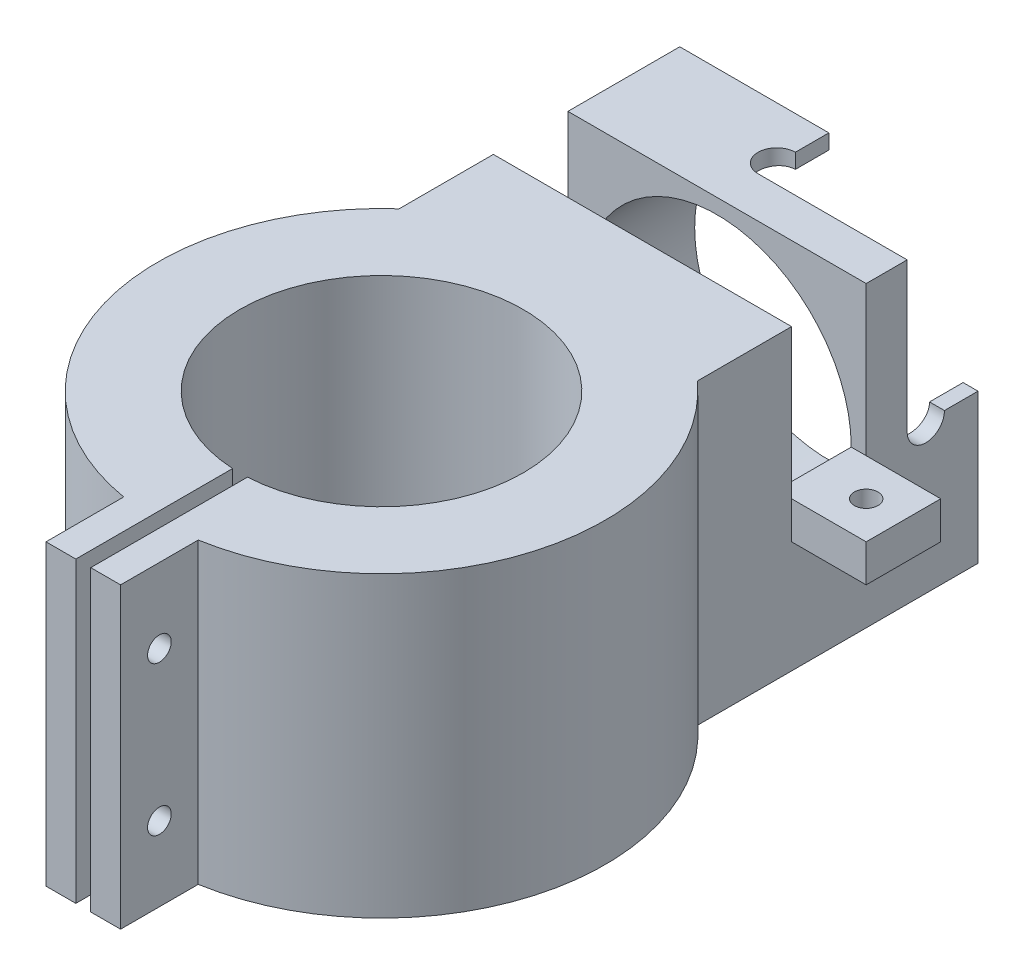
from build123d import *

# Parameters (mm, degrees)
SKETCH1_R           = 19
BOSS_EXTRUDE1_DEPTH = 40
SKETCH4_W           = 40
SKETCH4_H           = 40
BOSS_EXTRUDE2_DEPTH = 30
SKETCH5_R           = 18
CUT_EXTRUDE3_DEPTH  = 30
SKETCH8_R           = 2.5
CUT_EXTRUDE5_DEPTH  = 10
SKETCH2_W           = 2
SKETCH2_H           = 21.052668078
CUT_EXTRUDE1_DEPTH  = 40
SKETCH3_R           = 1.5875
CUT_EXTRUDE2_DEPTH  = 35
SKETCH9_W           = 40
SKETCH9_H           = 10
CUT_EXTRUDE6_DEPTH  = 20
SKETCH10_W          = 10
SKETCH10_H          = 5
BOSS_EXTRUDE3_DEPTH = 10
SKETCH11_R          = 1.5875
CUT_EXTRUDE7_DEPTH  = 5
SKETCH12_W          = 20
SKETCH12_H          = 20
CUT_EXTRUDE9_DEPTH  = 2.5
CUT_EXTRUDE10_REACH = 52
SKETCH13_R          = 2.5
SKETCH14_W          = 20
SKETCH14_H          = 20
CUT_EXTRUDE11_DEPTH = 4.5


with BuildPart() as part:
    # Sketch1 → Boss-Extrude1 (new body)
    with BuildSketch(Plane(origin=(0, 0, 0), x_dir=(1, 0, 0), z_dir=(0, 1, 0))):
        with BuildLine():
            Line((5, -40), (-5, -40))
            Line((-5, -40), (-5, -29.580398915))
            ThreePointArc((-5, -29.580398915), (-28.822194814, -8.323526063), (-20, 22.360679775))
            Line((-20, 22.360679775), (-20, 30))
            Line((-20, 30), (20, 30))
            Line((20, 30), (20, 22.360679775))
            ThreePointArc((20, 22.360679775), (28.822194814, -8.323526063), (5, -29.580398915))
            Line((5, -29.580398915), (5, -40))
        make_face()
        Circle(SKETCH1_R, mode=Mode.SUBTRACT)
    extrude(amount=BOSS_EXTRUDE1_DEPTH)

    # Sketch4 → Boss-Extrude2 (add)
    with BuildSketch(Plane(origin=(0, 0, -30), x_dir=(-1, 0, 0), z_dir=(0, 0, -1))):
        with Locations((0, 20)):
            Rectangle(SKETCH4_W, SKETCH4_H)
    extrude(amount=BOSS_EXTRUDE2_DEPTH)

    # Sketch5 → Cut-Extrude3 (cut)
    with BuildSketch(Plane(origin=(0, 0, -60), x_dir=(-1, 0, 0), z_dir=(0, 0, -1))):
        with Locations((0, 20)):
            Circle(SKETCH5_R)
    extrude(amount=-CUT_EXTRUDE3_DEPTH, mode=Mode.SUBTRACT)

    # Sketch8 → Cut-Extrude5 (cut)
    with BuildSketch(Plane(origin=(0, 40, 0), x_dir=(1, 0, 0), z_dir=(0, 1, 0))):
        with Locations((0, 53)):
            Circle(SKETCH8_R)
    extrude(amount=-CUT_EXTRUDE5_DEPTH, mode=Mode.SUBTRACT)

    # Sketch2 → Cut-Extrude1 (cut)
    with BuildSketch(Plane(origin=(0, 40, 0), x_dir=(1, 0, 0), z_dir=(0, 1, 0))):
        with Locations((0, -29.5)):
            Rectangle(SKETCH2_W, SKETCH2_H)
    extrude(amount=-CUT_EXTRUDE1_DEPTH, mode=Mode.SUBTRACT)

    # Sketch3 → Cut-Extrude2 (cut)
    with BuildSketch(Plane(origin=(5, 0, 0), x_dir=(0, 0, -1), z_dir=(1, 0, 0))):
        with Locations((-34.790199458, 30)):
            Circle(SKETCH3_R)
        with Locations((-34.790199458, 10)):
            Circle(SKETCH3_R)
    extrude(amount=-CUT_EXTRUDE2_DEPTH, mode=Mode.SUBTRACT)

    # Sketch9 → Cut-Extrude6 (cut)
    with BuildSketch(Plane(origin=(0, 40, 0), x_dir=(1, 0, 0), z_dir=(0, 1, 0))):
        with Locations((0, 40)):
            Rectangle(SKETCH9_W, SKETCH9_H)
    extrude(amount=-CUT_EXTRUDE6_DEPTH, mode=Mode.SUBTRACT)

    # Sketch10 → Boss-Extrude3 (add)
    with BuildSketch(Plane.ZY.offset(20)):
        with Locations((-40, 17.5)):
            Rectangle(SKETCH10_W, SKETCH10_H)
    boss_extrude3 = extrude(amount=BOSS_EXTRUDE3_DEPTH)

    # Sketch11 → Cut-Extrude7 (cut)
    with BuildSketch(Plane(origin=(0, 20, 0), x_dir=(1, 0, 0), z_dir=(0, 1, 0))):
        with Locations((-25, 40)):
            Circle(SKETCH11_R)
    cut_extrude7 = extrude(amount=-CUT_EXTRUDE7_DEPTH, mode=Mode.SUBTRACT)

    # Mirror1: Boss-Extrude3, Cut-Extrude7 across plane
    add(boss_extrude3.mirror(Plane(origin=(0, 0, 0), x_dir=(0, 0, 1), z_dir=(1, 0, 0))))
    add(cut_extrude7.mirror(Plane(origin=(0, 0, 0), x_dir=(0, 0, 1), z_dir=(1, 0, 0))), mode=Mode.SUBTRACT)

    # Sketch12 → Cut-Extrude9 (cut, symmetric)
    with BuildSketch(Plane(origin=(0, 0, -53), x_dir=(-1, 0, 0), z_dir=(0, 0, -1))):
        with Locations((-10, 30)):
            Rectangle(SKETCH12_W, SKETCH12_H)
    extrude(amount=CUT_EXTRUDE9_DEPTH, both=True, mode=Mode.SUBTRACT)

    # Sketch13 → Cut-Extrude10 (cut, up to next)
    with BuildSketch(Plane(origin=(20, 0, 0), x_dir=(0, 0, -1), z_dir=(1, 0, 0)), mode=Mode.PRIVATE) as cut_extrude10_sk1:
        with Locations((53, 20)):
            Circle(SKETCH13_R)
    cut_extrude10_tool1 = extrude(cut_extrude10_sk1.sketch, amount=-CUT_EXTRUDE10_REACH, mode=Mode.PRIVATE) & part.part
    add(cut_extrude10_tool1.solids().sort_by_distance((20, 20, -53))[0], mode=Mode.SUBTRACT)

    # Sketch14 → Cut-Extrude11 (cut)
    with BuildSketch(Plane.XY.offset(-55.5)):
        with Locations((10, 30)):
            Rectangle(SKETCH14_W, SKETCH14_H)
    extrude(amount=-CUT_EXTRUDE11_DEPTH, mode=Mode.SUBTRACT)


solid = part.part
